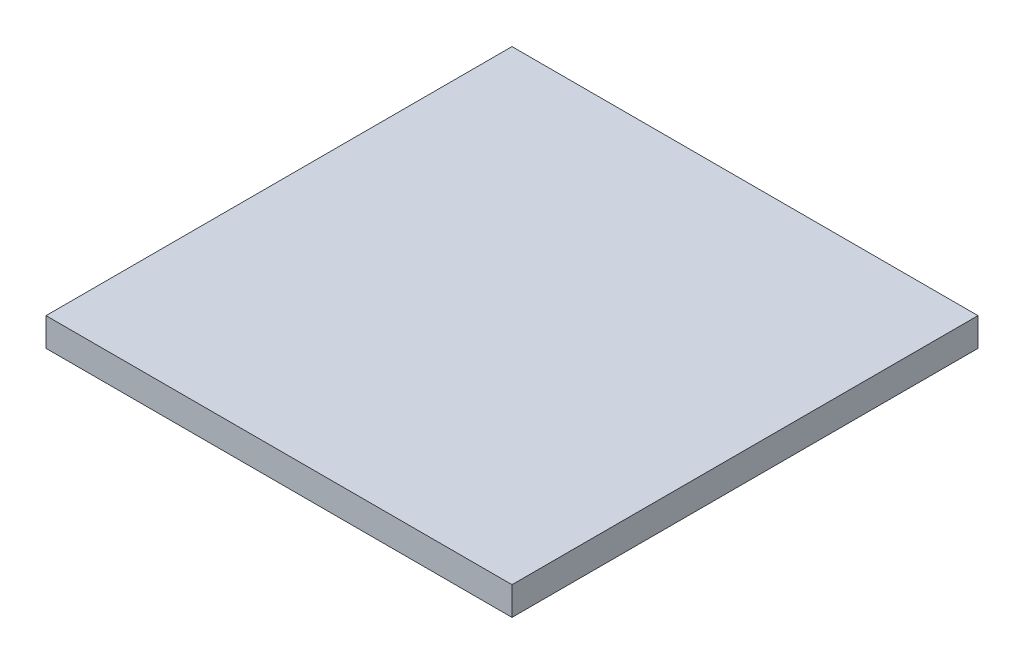
from build123d import *

# Parameters (mm, degrees)
SZKIC1_W                    = 345
SZKIC1_H                    = 345
DODANIE_WYCI_GNI_CIE1_DEPTH = 21


with BuildPart() as part:
    # Szkic1 → Dodanie-wyciągnięcie1 (new body)
    with BuildSketch(Plane(origin=(0, 0, 0), x_dir=(1, 0, 0), z_dir=(0, 1, 0))):
        with Locations((172.5, -172.5)):
            Rectangle(SZKIC1_W, SZKIC1_H)
    extrude(amount=DODANIE_WYCI_GNI_CIE1_DEPTH)


solid = part.part
